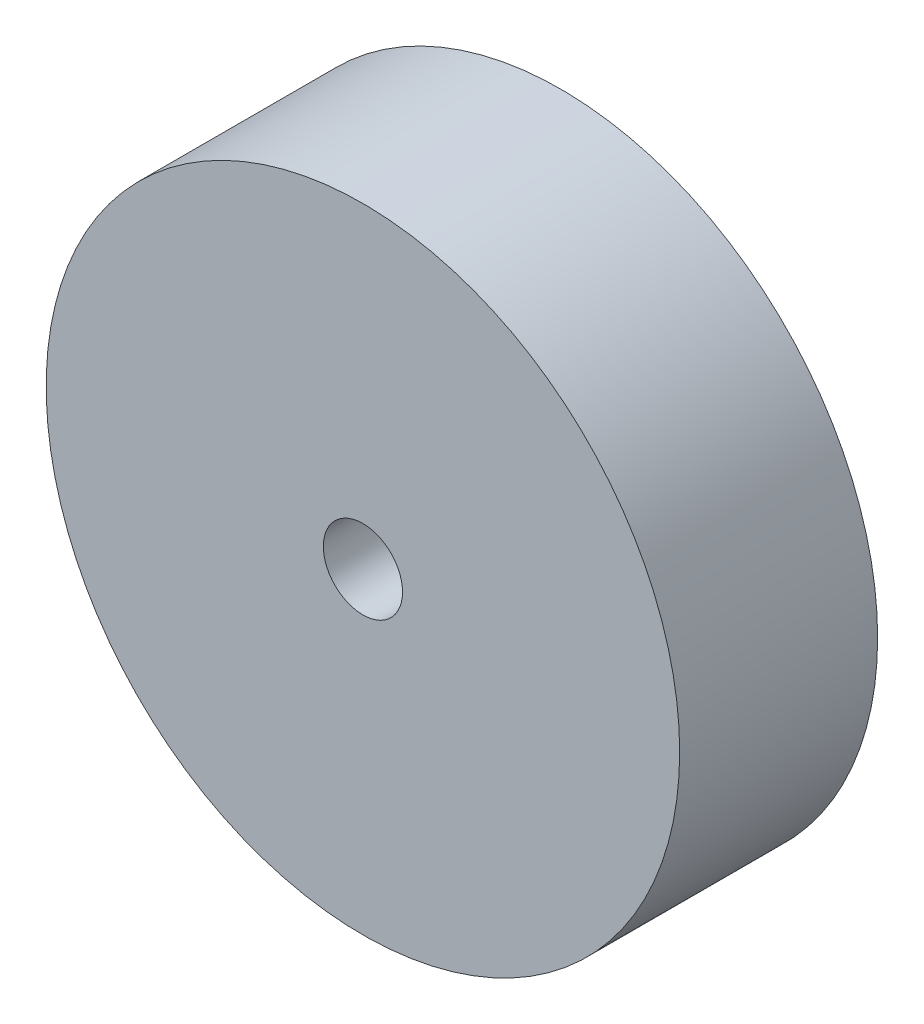
from build123d import *

# Parameters (mm, degrees)
CROQUIS1_R              = 20
SALIENTE_EXTRUIR1_DEPTH = 12.5
CROQUIS2_R              = 2.5
CORTAR_EXTRUIR1_DEPTH   = 12.5


with BuildPart() as part:
    # Croquis1 → Saliente-Extruir1 (new body)
    with BuildSketch(Plane.XY):
        Circle(CROQUIS1_R)
    extrude(amount=SALIENTE_EXTRUIR1_DEPTH)

    # Croquis2 → Cortar-Extruir1 (cut)
    with BuildSketch(Plane.XY.offset(12.5)):
        Circle(CROQUIS2_R)
    extrude(amount=-CORTAR_EXTRUIR1_DEPTH, mode=Mode.SUBTRACT)


solid = part.part
